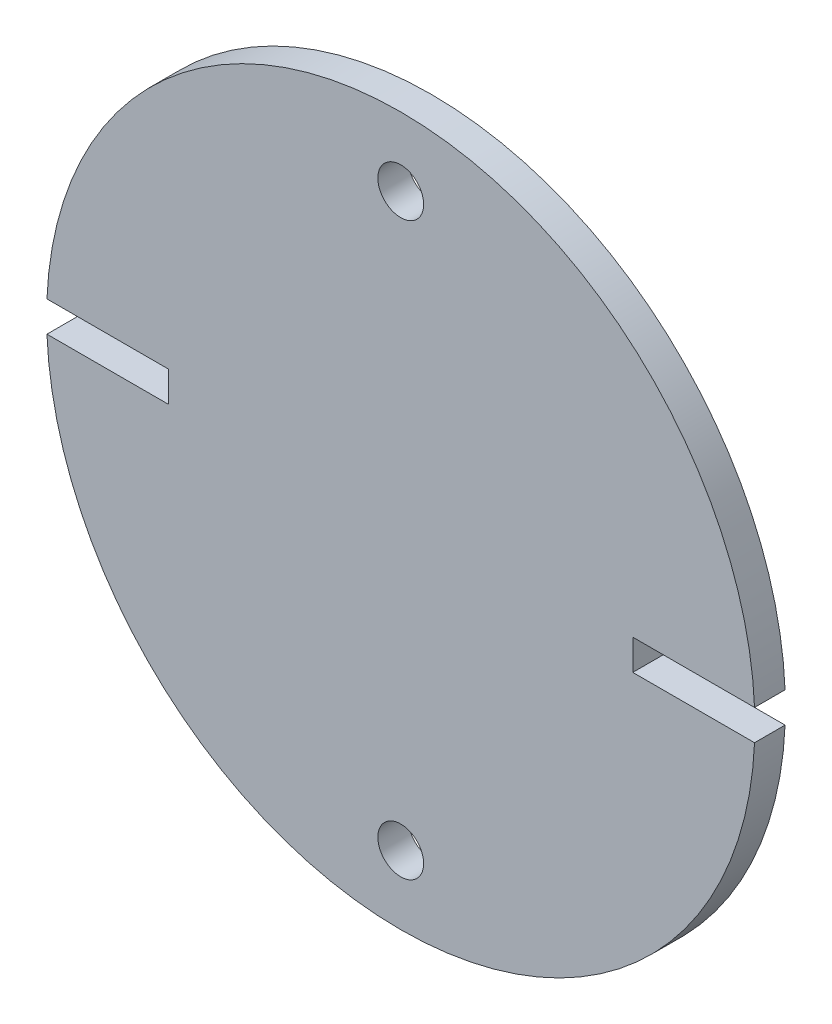
from build123d import *

# Parameters (mm, degrees)
SKETCH1_R           = 73.66
BOSS_EXTRUDE1_DEPTH = 6.35
CUT_EXTRUDE1_DEPTH  = 7.35
SKETCH4_R           = 4.7625
CUT_EXTRUDE2_DEPTH  = 7.35


with BuildPart() as part:
    # Sketch1 → Boss-Extrude1 (new body)
    with BuildSketch(Plane.XY):
        Circle(SKETCH1_R)
    extrude(amount=BOSS_EXTRUDE1_DEPTH)

    # Sketch2 → Cut-Extrude1 (cut, through all)
    with BuildSketch(Plane(origin=(0, 0, 0), x_dir=(-1, 0, 0), z_dir=(0, 0, -1))):
        Polygon((-48.26, 0), (-48.26, 3.175), (-76.2, 3.175), (-76.2, -3.175), (-48.26, -3.175), align=None)
        Polygon((48.26, -3.175), (48.26, 0), (48.26, 3.175), (76.2, 3.175), (76.2, -3.175), align=None)
    extrude(amount=-CUT_EXTRUDE1_DEPTH, mode=Mode.SUBTRACT)

    # Sketch4 → Cut-Extrude2 (cut, through all)
    with BuildSketch(Plane(origin=(0, 0, 0), x_dir=(-1, 0, 0), z_dir=(0, 0, -1))):
        with Locations((0, -59.3725)):
            Circle(SKETCH4_R)
        with Locations((0, 59.3725)):
            Circle(SKETCH4_R)
    extrude(amount=-CUT_EXTRUDE2_DEPTH, mode=Mode.SUBTRACT)


solid = part.part
